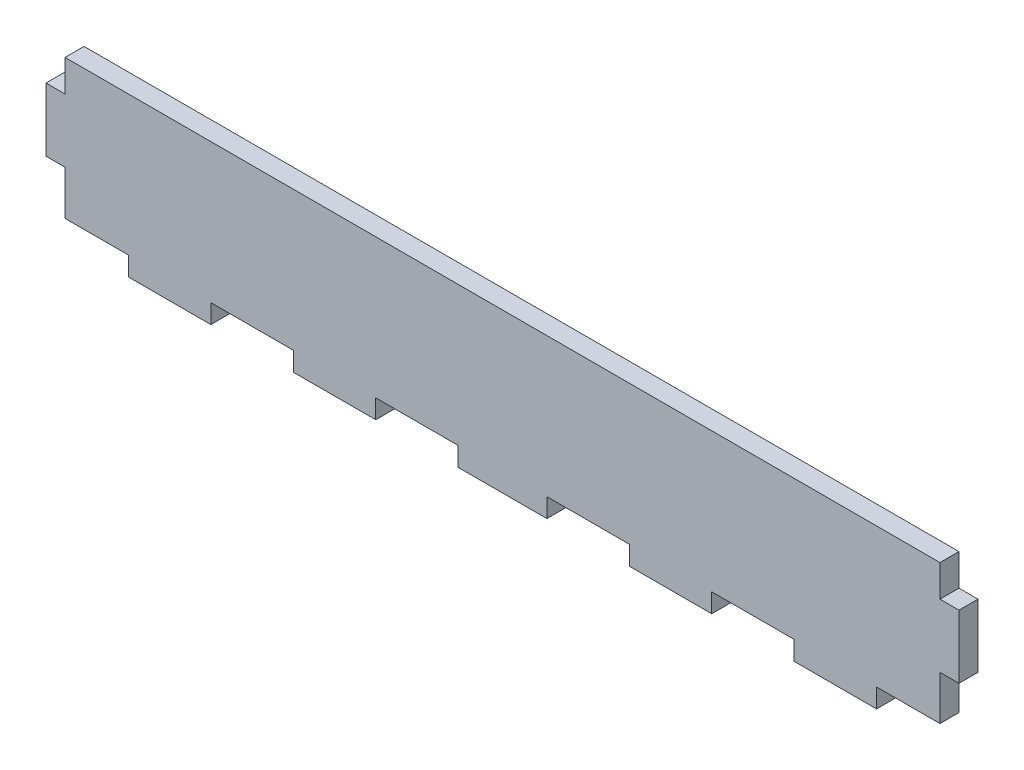
from build123d import *

# Parameters (mm, degrees)
BOSS_EXTRUDE1_DEPTH = 3


with BuildPart() as part:
    # Sketch1 → Boss-Extrude1 (new body)
    with BuildSketch(Plane.XY):
        Polygon((0, 17), (0, 22), (138, 22), (138, 17), (141, 17), (141, 7), (138, 7), (138, 0), (128, 0), (128, -3), (115, -3), (115, 0), (102, 0), (102, -3), (89, -3), (89, 0), (76, 0), (76, -3), (62, -3), (62, 0), (49, 0), (49, -3), (36, -3), (36, 0), (23, 0), (23, -3), (10, -3), (10, 0), (0, 0), (0, 7), (-3, 7), (-3, 17), align=None)
    extrude(amount=BOSS_EXTRUDE1_DEPTH)


solid = part.part
